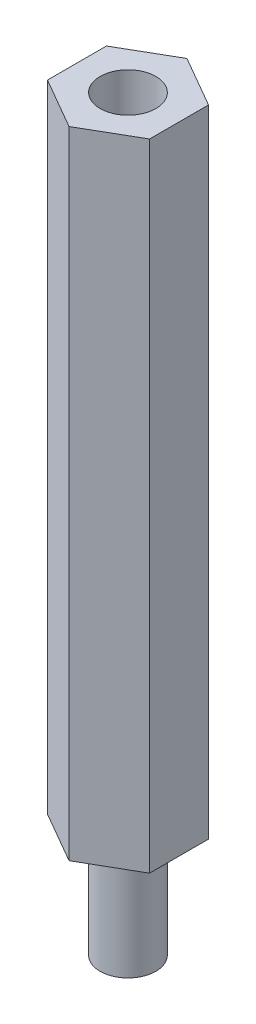
from build123d import *

# Parameters (mm, degrees)
SKETCH1_R           = 1.524
BOSS_EXTRUDE1_DEPTH = 34.798
SKETCH1_3_R         = 1.524
BOSS_EXTRUDE2_DEPTH = 6.096
CUT_EXTRUDE1_START  = 34.798
SKETCH1_4_R         = 1.524
CUT_EXTRUDE1_DEPTH  = 6.096


with BuildPart() as part:
    # Sketch1 → Boss-Extrude1 (new body)
    with BuildSketch(Plane(origin=(0, 0, 0), x_dir=(1, 0, 0), z_dir=(0, 1, 0))):
        Polygon((-2.794, -1.613116652), (0, -3.226233304), (2.794, -1.613116652), (2.794, 1.613116652), (0, 3.226233304), (-2.794, 1.613116652), align=None)
        Circle(SKETCH1_R, mode=Mode.SUBTRACT)
        Circle(SKETCH1_R)
    extrude(amount=BOSS_EXTRUDE1_DEPTH)

    # Sketch1_3 → Boss-Extrude2 (add)
    with BuildSketch(Plane(origin=(0, 0, 0), x_dir=(1, 0, 0), z_dir=(0, 1, 0))):
        with Locations(Location((0, 0, 0), (0, 0, 270))):
            Circle(SKETCH1_3_R)
    extrude(amount=-BOSS_EXTRUDE2_DEPTH)

    # Sketch1_4 → Cut-Extrude1 (cut)
    with BuildSketch(Plane(origin=(0, 0, 0), x_dir=(1, 0, 0), z_dir=(0, 1, 0)).offset(CUT_EXTRUDE1_START)):
        with Locations(Location((0, 0, 0), (0, 0, 270))):
            Circle(SKETCH1_4_R)
    extrude(amount=-CUT_EXTRUDE1_DEPTH, mode=Mode.SUBTRACT)


solid = part.part
